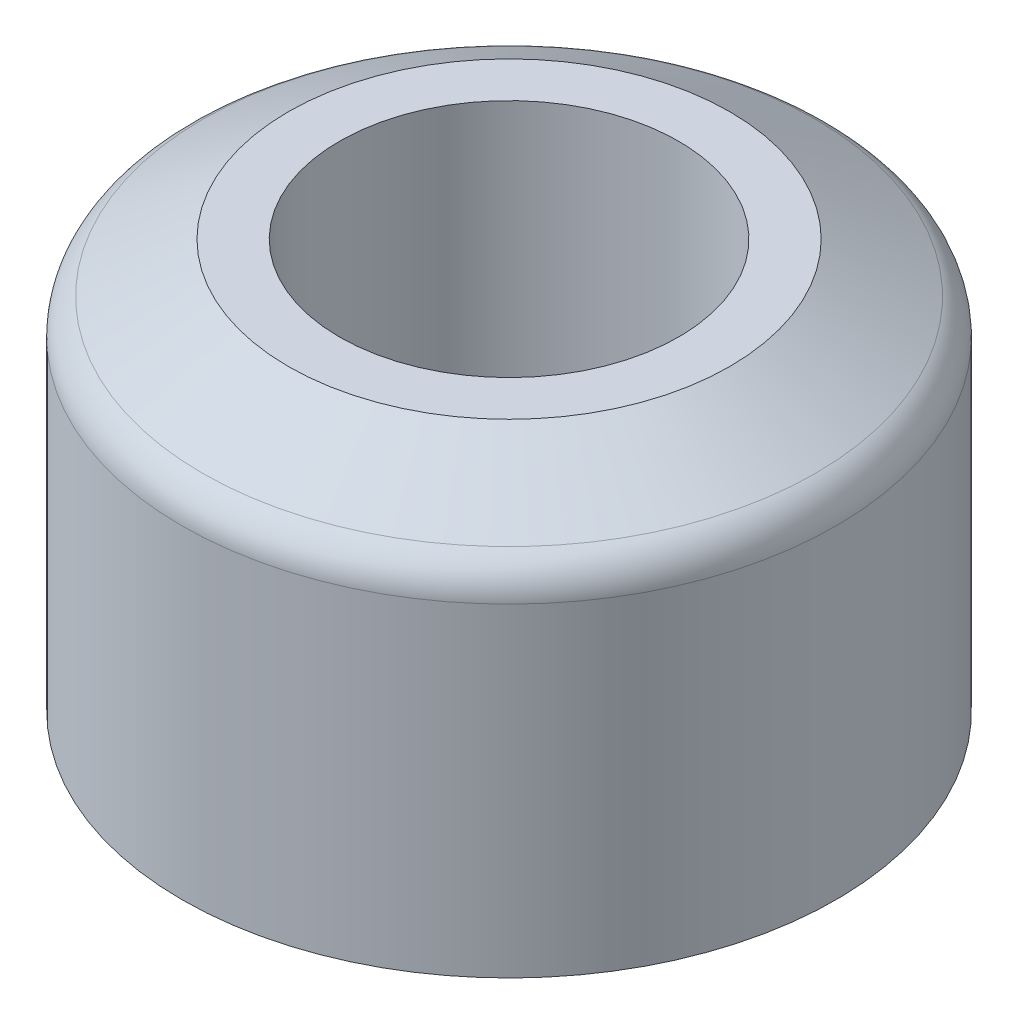
from build123d import *

# Parameters (mm, degrees)
SKETCH1_R           = 8
SKETCH1_R_2         = 4.15
BOSS_EXTRUDE1_DEPTH = 10
CHAMFER1_SIZE       = 2.6
CHAMFER1_SIZE2      = 1.5011107
FILLET1_R           = 1


with BuildPart() as part:
    # Sketch1 → Boss-Extrude1 (new body)
    with BuildSketch(Plane(origin=(0, 0, 0), x_dir=(1, 0, 0), z_dir=(0, 1, 0))):
        Circle(SKETCH1_R)
        Circle(SKETCH1_R_2, mode=Mode.SUBTRACT)
    extrude(amount=BOSS_EXTRUDE1_DEPTH)

    # Chamfer1
    chamfer1_edges = [part.edges().sort_by_distance(p)[0] for p in [
        (-8, 10, 0),
    ]]
    chamfer1_side = [part.faces().sort_by_distance(p)[0] for p in [
        (-7.77372583, 10, 0),
    ]]
    chamfer(chamfer1_edges, length=CHAMFER1_SIZE, length2=CHAMFER1_SIZE2, reference=chamfer1_side[0])

    # Fillet1
    fillet1_edges = [part.edges().sort_by_distance(p)[0] for p in [
        (-8, 8.4988893, 0),
    ]]
    fillet(fillet1_edges, radius=FILLET1_R)


solid = part.part
